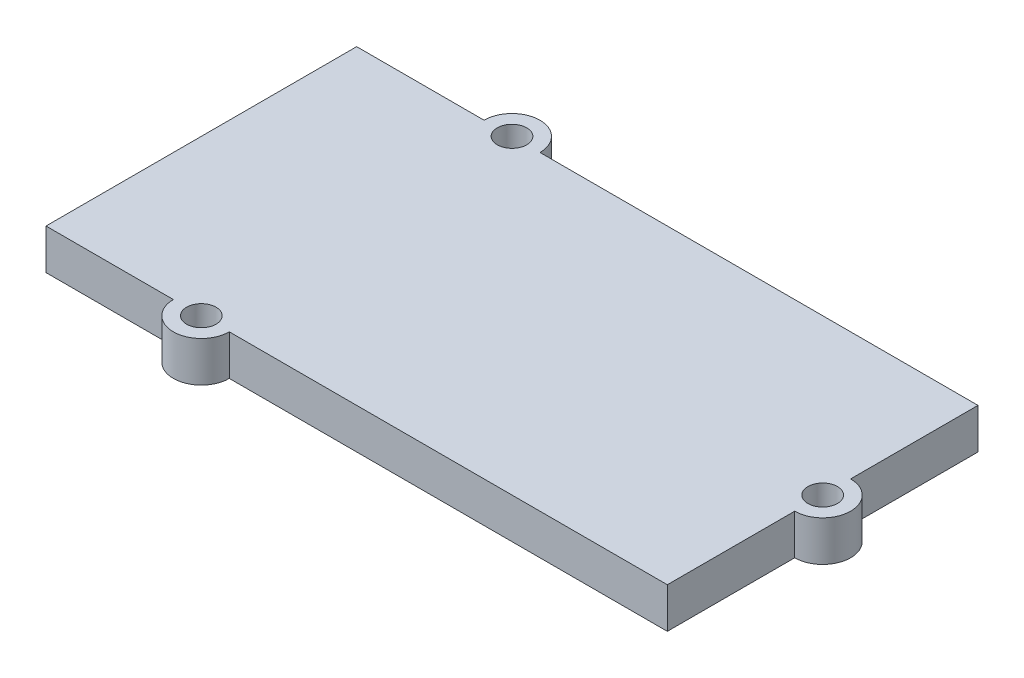
from build123d import *

# Parameters (mm, degrees)
SKETCH1_R           = 0.95
BOSS_EXTRUDE1_DEPTH = 2.6


with BuildPart() as part:
    # Sketch1 → Boss-Extrude1 (new body)
    with BuildSketch(Plane(origin=(0, 0, 0), x_dir=(1, 0, 0), z_dir=(0, 1, 0))):
        with BuildLine():
            Line((20, -8.2), (20, 0))
            Line((20, 0), (-8.2, 0))
            ThreePointArc((-8.2, 0), (-10, 1.8), (-11.8, 0))
            Line((-11.8, 0), (-20, 0))
            Line((-20, 0), (-20, -20))
            Line((-20, -20), (-11.8, -20))
            ThreePointArc((-11.8, -20), (-10, -21.8), (-8.2, -20))
            Line((-8.2, -20), (20, -20))
            Line((20, -20), (20, -11.8))
            ThreePointArc((20, -11.8), (21.8, -10), (20, -8.2))
        make_face()
        with Locations((-10, 0)):
            Circle(SKETCH1_R, mode=Mode.SUBTRACT)
        with Locations((20, -10)):
            Circle(SKETCH1_R, mode=Mode.SUBTRACT)
        with Locations((-10, -20)):
            Circle(SKETCH1_R, mode=Mode.SUBTRACT)
    extrude(amount=BOSS_EXTRUDE1_DEPTH)


solid = part.part
